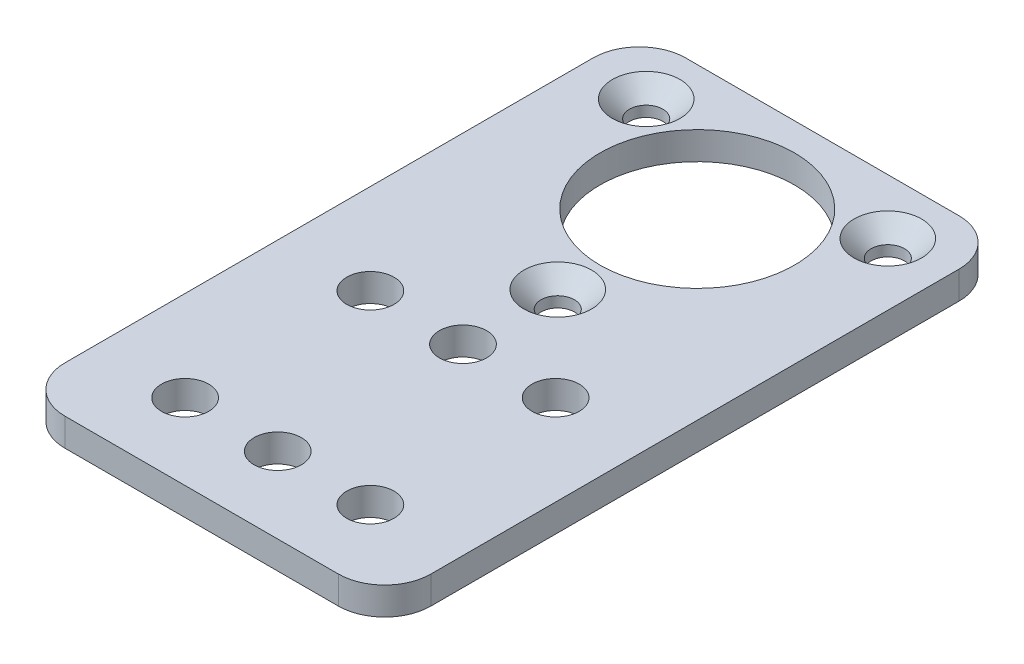
from build123d import *

# Parameters (mm, degrees)
SKETCH1_R                                      = 2.55
BOSS_EXTRUDE1_DEPTH                            = 3
SKETCH2_R                                      = 10.5
CUT_EXTRUDE2_DEPTH                             = 4
CSK_FOR_M3_FLAT_HEAD_MACHINE_SCREW1_AT_2_COUNT = 2
CSK_FOR_M3_FLAT_HEAD_MACHINE_SCREW1_AT_2_PITCH = 26.084685162
CSK_FOR_M3_FLAT_HEAD_MACHINE_SCREW1_AT_3_COUNT = 2
CSK_FOR_M3_FLAT_HEAD_MACHINE_SCREW1_AT_3_PITCH = 26.084685162


with BuildPart() as part:
    # Sketch1 → Boss-Extrude1 (new body)
    with BuildSketch(Plane(origin=(0, 0, 0), x_dir=(1, 0, 0), z_dir=(0, 1, 0))):
        with BuildLine():
            Line((14.75, -33.5), (-14.75, -33.5))
            ThreePointArc((-14.75, -33.5), (-18.285533906, -32.035533906), (-19.75, -28.5))
            Line((-19.75, -28.5), (-19.75, 28.5))
            ThreePointArc((-19.75, 28.5), (-18.285533906, 32.035533906), (-14.75, 33.5))
            Line((-14.75, 33.5), (14.75, 33.5))
            ThreePointArc((14.75, 33.5), (18.285533906, 32.035533906), (19.75, 28.5))
            Line((19.75, 28.5), (19.75, -28.5))
            ThreePointArc((19.75, -28.5), (18.285533906, -32.035533906), (14.75, -33.5))
        make_face()
        with Locations((0, 26.5)):
            Circle(SKETCH1_R, mode=Mode.SUBTRACT)
        with Locations((10, -25.29)):
            Circle(SKETCH1_R, mode=Mode.SUBTRACT)
        with Locations((10, -5.29)):
            Circle(SKETCH1_R, mode=Mode.SUBTRACT)
        with Locations((0, -25.29)):
            Circle(SKETCH1_R, mode=Mode.SUBTRACT)
        with Locations((0, -5.29)):
            Circle(SKETCH1_R, mode=Mode.SUBTRACT)
        with Locations((-10, -25.29)):
            Circle(SKETCH1_R, mode=Mode.SUBTRACT)
        with Locations((-10, -5.29)):
            Circle(SKETCH1_R, mode=Mode.SUBTRACT)
    extrude(amount=BOSS_EXTRUDE1_DEPTH)

    # Sketch2 → Cut-Extrude2 (cut, through all)
    with BuildSketch(Plane(origin=(0, 3, 0), x_dir=(1, 0, 0), z_dir=(0, 1, 0))):
        with Locations((0, 20)):
            Circle(SKETCH2_R)
    extrude(amount=-CUT_EXTRUDE2_DEPTH, mode=Mode.SUBTRACT)

    # Sketch4 → CSK for M3 Flat Head Machine Screw1 (revolve, cut)
    with BuildSketch(Plane(origin=(-13.042342581, 3, -27.53), x_dir=(0, 0, 1), z_dir=(1, 0, 0))):
        Polygon((0, 0), (0, 3), (1.8, 3), (1.8, 1.85), (3.65, 0), align=None)
    csk_for_m3_flat_head_machine_screw1 = revolve(axis=Axis((-13.042342581, 9.35, -27.53), (0, -1, 0)), mode=Mode.SUBTRACT)

    # CSK for M3 Flat Head Machine Screw1 at 2: CSK for M3 Flat Head Machine Screw1 ×2
    with Locations(*[(i * CSK_FOR_M3_FLAT_HEAD_MACHINE_SCREW1_AT_2_PITCH, 0, 0) for i in range(1, CSK_FOR_M3_FLAT_HEAD_MACHINE_SCREW1_AT_2_COUNT)]):
        add(csk_for_m3_flat_head_machine_screw1, mode=Mode.SUBTRACT)

    # CSK for M3 Flat Head Machine Screw1 at 3: CSK for M3 Flat Head Machine Screw1 ×2
    with Locations(*[Vector(0.5, 0, 0.866025404) * (i * CSK_FOR_M3_FLAT_HEAD_MACHINE_SCREW1_AT_3_PITCH) for i in range(1, CSK_FOR_M3_FLAT_HEAD_MACHINE_SCREW1_AT_3_COUNT)]):
        add(csk_for_m3_flat_head_machine_screw1, mode=Mode.SUBTRACT)


solid = part.part
